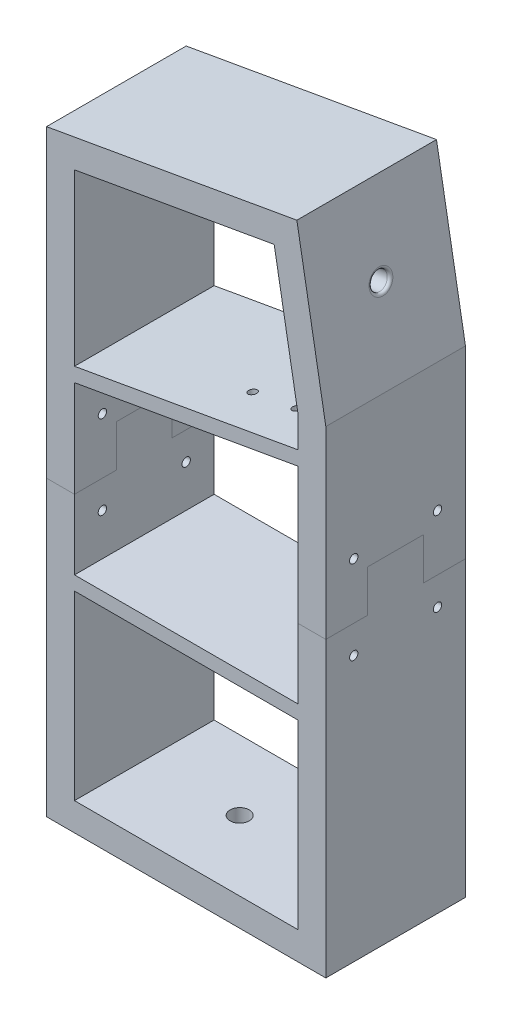
from build123d import *

# Parameters (mm, degrees)
BOSS_EXTRUDE1_DEPTH    = 50
SKETCH4_R              = 3.2
CUT_EXTRUDE1_DEPTH     = 10
BOSS_EXTRUDE2_DEPTH    = 50
SKETCH8_R              = 5
CUT_EXTRUDE3_DEPTH     = 10
CUT_EXTRUDE4_REACH     = 254.527
SKETCH9_R              = 1.485
SKETCH10_R             = 3.425
CUT_EXTRUDE5_DEPTH     = 10
SKETCH11_W             = 80
SKETCH11_H             = 5
BOSS_EXTRUDE3_DEPTH    = 50
FILLET1_R              = 1
SKETCH13_R             = 1.5
CUT_EXTRUDE6_DEPTH     = 256.567325306
SPLIT1_SURFACE_1_BACK  = 256.567
SPLIT1_SURFACE_1_DEPTH = 513.134
SPLIT1_SURFACE_2_BACK  = 256.567
SPLIT1_SURFACE_2_DEPTH = 513.134


with BuildPart() as part:
    # Sketch2 → Boss-Extrude1 (new body)
    with BuildSketch(Plane.XY):
        Polygon((-50, 214.01), (-50, 0), (50, 0), (50, 171.01), (39.631197958, 229.814398513), align=None)
        Polygon((-40, 205.619003688), (-40, 10), (40, 10), (40, 170.135113365), (31.519602204, 218.229839206), align=None, mode=Mode.SUBTRACT)
    extrude(amount=BOSS_EXTRUDE1_DEPTH)

    # Sketch4 → Cut-Extrude1 (cut)
    with BuildSketch(Plane(origin=(77.736747875, 13.707086043, 0), x_dir=(0, 0, -1), z_dir=(0.9848077530122079, 0.17364817766693136, 0))):
        with Locations(Location((-25, 190.058116105, 0), (0, 0, 90))):
            Circle(SKETCH4_R)
    extrude(amount=-CUT_EXTRUDE1_DEPTH, mode=Mode.SUBTRACT)

    # Sketch7 → Boss-Extrude2 (add)
    with BuildSketch(Plane.XY.offset(50)):
        Polygon((40, 158.799565432), (40, 153.722432372), (-40, 139.616273916), (-40, 144.693406975), align=None)
    extrude(amount=-BOSS_EXTRUDE2_DEPTH)

    # Sketch8 → Cut-Extrude3 (cut)
    with BuildSketch(Plane.ZY.offset(50)):
        with Locations(Location((25, 193.163858422, 0), (0, 0, 270))):
            Circle(SKETCH8_R)
    extrude(amount=-CUT_EXTRUDE3_DEPTH, mode=Mode.SUBTRACT)

    # Sketch9 → Cut-Extrude4 (cut, up to next)
    with BuildSketch(Plane(origin=(130.25849011, 169.637439417, 0), x_dir=(-0.9848077530122079, -0.17364817766693152, 0), z_dir=(-0.17364817766693152, 0.9848077530122079, 0)), mode=Mode.PRIVATE) as cut_extrude4_sk1:
        with Locations((106.879323392, 15.4)):
            Circle(SKETCH9_R)
    cut_extrude4_tool1 = extrude(cut_extrude4_sk1.sketch, amount=CUT_EXTRUDE4_REACH, mode=Mode.PRIVATE) & part.part
    # Sketch9 → Cut-Extrude4 (cut, up to next)
    with BuildSketch(Plane(origin=(130.25849011, 169.637439417, 0), x_dir=(-0.9848077530122079, -0.17364817766693152, 0), z_dir=(-0.17364817766693152, 0.9848077530122079, 0)), mode=Mode.PRIVATE) as cut_extrude4_sk2:
        with Locations((106.879323392, 34.6)):
            Circle(SKETCH9_R)
    cut_extrude4_tool2 = extrude(cut_extrude4_sk2.sketch, amount=CUT_EXTRUDE4_REACH, mode=Mode.PRIVATE) & part.part
    # Sketch9 → Cut-Extrude4 (cut, up to next)
    with BuildSketch(Plane(origin=(130.25849011, 169.637439417, 0), x_dir=(-0.9848077530122079, -0.17364817766693152, 0), z_dir=(-0.17364817766693152, 0.9848077530122079, 0)), mode=Mode.PRIVATE) as cut_extrude4_sk3:
        with Locations(Location((122.879323392, 34.6, 0), (0, 0, 180))):
            Circle(SKETCH9_R)
    cut_extrude4_tool3 = extrude(cut_extrude4_sk3.sketch, amount=CUT_EXTRUDE4_REACH, mode=Mode.PRIVATE) & part.part
    # Sketch9 → Cut-Extrude4 (cut, up to next)
    with BuildSketch(Plane(origin=(130.25849011, 169.637439417, 0), x_dir=(-0.9848077530122079, -0.17364817766693152, 0), z_dir=(-0.17364817766693152, 0.9848077530122079, 0)), mode=Mode.PRIVATE) as cut_extrude4_sk4:
        with Locations(Location((122.879323392, 15.4, 0), (0, 0, 180))):
            Circle(SKETCH9_R)
    cut_extrude4_tool4 = extrude(cut_extrude4_sk4.sketch, amount=CUT_EXTRUDE4_REACH, mode=Mode.PRIVATE) & part.part
    add(cut_extrude4_tool1.solids().sort_by_distance((25.002904, 151.07804, 15.4))[0], mode=Mode.SUBTRACT)
    add(cut_extrude4_tool2.solids().sort_by_distance((25.002904, 151.07804, 34.6))[0], mode=Mode.SUBTRACT)
    add(cut_extrude4_tool3.solids().sort_by_distance((9.24598, 148.299669, 34.6))[0], mode=Mode.SUBTRACT)
    add(cut_extrude4_tool4.solids().sort_by_distance((9.24598, 148.299669, 15.4))[0], mode=Mode.SUBTRACT)

    # Sketch10 → Cut-Extrude5 (cut)
    with BuildSketch(Plane(origin=(0, 10, 0), x_dir=(1, 0, 0), z_dir=(0, 1, 0))):
        with Locations(Location((-5.851287133, -25, 0), (0, 0, 180))):
            Circle(SKETCH10_R)
        with Locations(Location((24.130974018, -25, 0), (0, 0, 180))):
            Circle(SKETCH10_R)
    extrude(amount=-CUT_EXTRUDE5_DEPTH, mode=Mode.SUBTRACT)

    # Sketch11 → Boss-Extrude3 (add)
    with BuildSketch(Plane.XY.offset(50)):
        with Locations((0, 77.5)):
            Rectangle(SKETCH11_W, SKETCH11_H)
    extrude(amount=-BOSS_EXTRUDE3_DEPTH)

    # Fillet1
    fillet1_edges = [part.edges().sort_by_distance(p)[0] for p in [
        (45.289176531, 197.726407497, 25),
    ]]
    fillet(fillet1_edges, radius=FILLET1_R)

    # Sketch13 → Cut-Extrude6 (cut, through all)
    with BuildSketch(Plane.ZY.offset(50)):
        with Locations(Location((40, 125, 0), (0, 0, 270))):
            Circle(SKETCH13_R)
        with Locations(Location((40, 95, 0), (0, 0, 270))):
            Circle(SKETCH13_R)
        with Locations((10, 95)):
            Circle(SKETCH13_R)
        with Locations((10, 125)):
            Circle(SKETCH13_R)
    extrude(amount=-CUT_EXTRUDE6_DEPTH, mode=Mode.SUBTRACT)


with BuildPart() as body_2:
    # Split1: the piece behind the surface
    add(part.part)
    # Split1 surface: a surface, the sketch's curves swept straight by 513.134 mm
    with BuildLine(Plane.ZY.offset(50).offset(-SPLIT1_SURFACE_1_BACK), mode=Mode.PRIVATE) as split1_surface_1_path:
        Line((50, 105), (35, 105))
        Line((35, 105), (35, 120))
        Line((35, 120), (15, 120))
        Line((15, 120), (15, 105))
        Line((15, 105), (0, 105))
    split1_surface_1 = Shell.extrude(split1_surface_1_path.wire(), (-1 * SPLIT1_SURFACE_1_DEPTH, 0 * SPLIT1_SURFACE_1_DEPTH, 0 * SPLIT1_SURFACE_1_DEPTH))
    split(bisect_by=split1_surface_1, keep=Keep.BOTTOM)


with BuildPart() as part_1:
    add(part.part)

    # Split1: split by a surface, the side it looks to stays
    # Split1 surface: a surface, the sketch's curves swept straight by 513.134 mm
    with BuildLine(Plane.ZY.offset(50).offset(-SPLIT1_SURFACE_2_BACK), mode=Mode.PRIVATE) as split1_surface_2_path:
        Line((50, 105), (35, 105))
        Line((35, 105), (35, 120))
        Line((35, 120), (15, 120))
        Line((15, 120), (15, 105))
        Line((15, 105), (0, 105))
    split1_surface_2 = Shell.extrude(split1_surface_2_path.wire(), (-1 * SPLIT1_SURFACE_2_DEPTH, 0 * SPLIT1_SURFACE_2_DEPTH, 0 * SPLIT1_SURFACE_2_DEPTH))
    split(bisect_by=split1_surface_2, keep=Keep.TOP)


solid = Compound([body_2.part, part_1.part])
